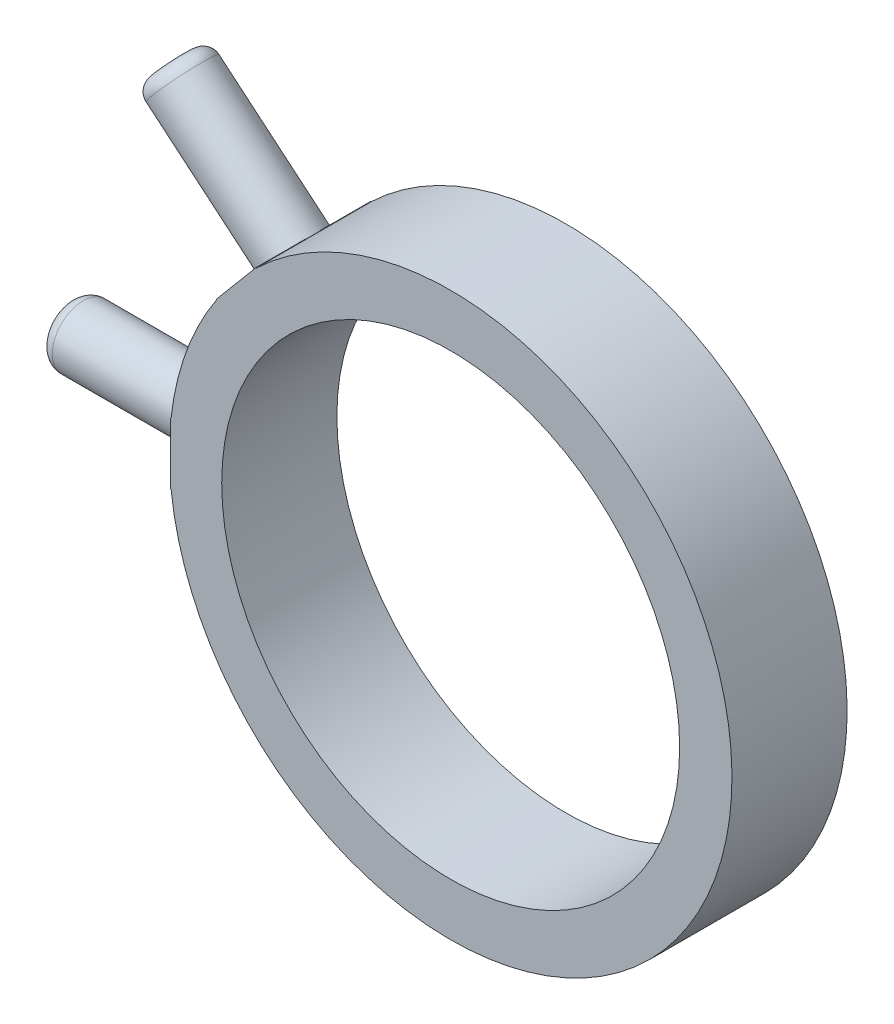
from build123d import *

# Parameters (mm, degrees)
ESQUISSE1_R             = 17.5
BOSS_EXTRU_1_DEPTH      = 8.8
ESQUISSE4_R             = 6.373182781
ESQUISSE4_R_2           = 2.35
ENL_V_MAT_EXTRU_1_DEPTH = 12.1
ESQUISSE5_R             = 10.689407939
ESQUISSE5_R_2           = 2.35
ENL_V_MAT_EXTRU_2_DEPTH = 12.1
CONG_1_R                = 1


with BuildPart() as part:
    # Esquisse1 → Boss.-Extru.1 (new body)
    with BuildSketch(Plane.XY):
        with BuildLine():
            Line((-33.5, 2.35), (-21.5, 2.35))
            Line((-21.5, 2.35), (-21.37118387, 2.35))
            ThreePointArc((-21.37118387, 2.35), (-20.203391347, 7.353433082), (-17.881827529, 11.936927755))
            Line((-17.881827529, 11.936927755), (-27.173039727, 19.733180483))
            Line((-27.173039727, 19.733180483), (-24.151937962, 23.333589366))
            Line((-24.151937962, 23.333589366), (-14.860725764, 15.537336637))
            ThreePointArc((-14.860725764, 15.537336637), (20.203391347, -7.353433082), (-21.37118387, -2.35))
            Line((-21.37118387, -2.35), (-21.5, -2.35))
            Line((-21.5, -2.35), (-33.5, -2.35))
            Line((-33.5, -2.35), (-33.5, 2.35))
        make_face()
        Circle(ESQUISSE1_R, mode=Mode.SUBTRACT)
    extrude(amount=BOSS_EXTRU_1_DEPTH)

    # Esquisse4 → Enlèv. mat.-Extru.1 (cut)
    with BuildSketch(Plane(origin=(-25.662488844, 21.533384924, 0), x_dir=(0, 0, 1), z_dir=(-0.766044443, 0.64278761, 0))):
        with Locations((4.4, 0)):
            Circle(ESQUISSE4_R)
        with Locations((4.4, 0)):
            Circle(ESQUISSE4_R_2, mode=Mode.SUBTRACT)
    extrude(amount=-ENL_V_MAT_EXTRU_1_DEPTH, mode=Mode.SUBTRACT)

    # Esquisse5 → Enlèv. mat.-Extru.2 (cut)
    with BuildSketch(Plane.ZY.offset(33.5)):
        with Locations((4.4, 0)):
            Circle(ESQUISSE5_R)
        with Locations((4.4, 0)):
            Circle(ESQUISSE5_R_2, mode=Mode.SUBTRACT)
    extrude(amount=-ENL_V_MAT_EXTRU_2_DEPTH, mode=Mode.SUBTRACT)

    # Congé1
    cong_1_edges = [part.edges().sort_by_distance(p)[0] for p in [
        (-25.662488844, 21.533384924, 2.05),
        (-33.5, 0, 2.05),
    ]]
    fillet(cong_1_edges, radius=CONG_1_R)


solid = part.part
